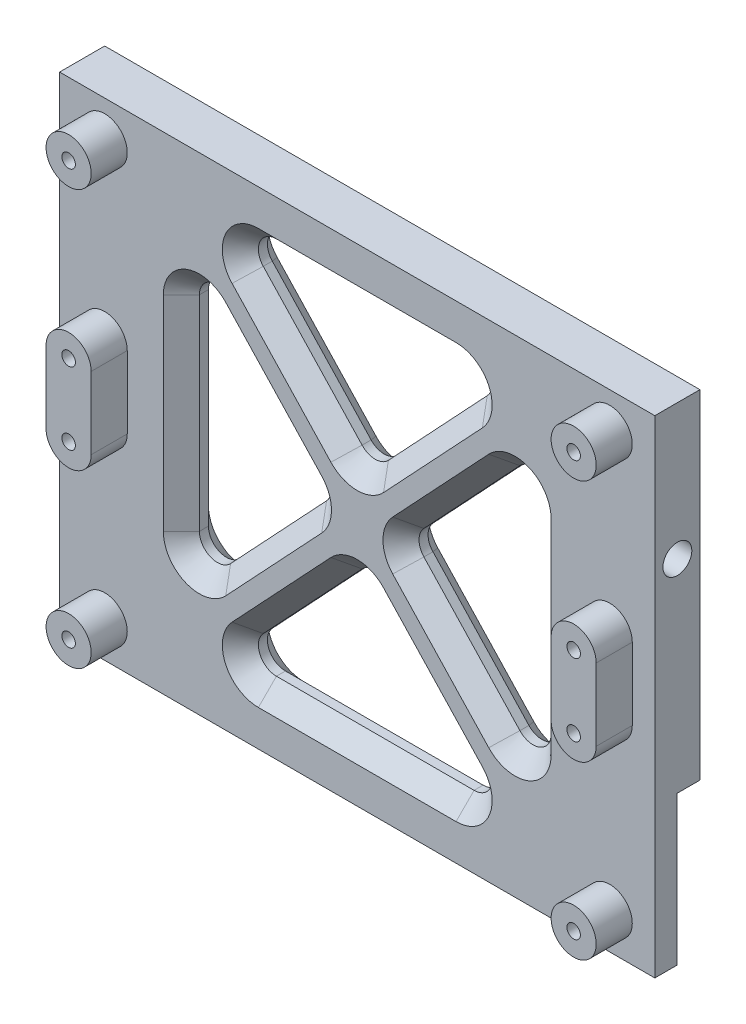
from build123d import *

# Parameters (mm, degrees)
SKETCH1_W           = 66
SKETCH1_H           = 54
BOSS_EXTRUDE1_DEPTH = 5
SKETCH2_R           = 2.5
SKETCH2_R_2         = 0.75
BOSS_EXTRUDE2_DEPTH = 4
SKETCH2_2_R         = 0.75
CUT_EXTRUDE1_DEPTH  = 4
CUT_EXTRUDE2_DEPTH  = 14
SKETCH4_R           = 1.6
SKETCH4_R_2         = 0.75
CUT_EXTRUDE3_DEPTH  = 5
CHAMFER1_SIZE       = 2
CUT_EXTRUDE4_START  = -66
SKETCH5_R           = 1.6
CUT_EXTRUDE4_DEPTH  = 10
SKETCH6_W           = 9.6
SKETCH6_H           = 16.5
CUT_EXTRUDE5_DEPTH  = 2.54


with BuildPart() as part:
    # Sketch1 → Boss-Extrude1 (new body)
    with BuildSketch(Plane.XY):
        Rectangle(SKETCH1_W, SKETCH1_H)
    extrude(amount=BOSS_EXTRUDE1_DEPTH)

    # Sketch2 → Boss-Extrude2 (add)
    with BuildSketch(Plane.XY.offset(5)):
        with Locations((28, -23)):
            Circle(SKETCH2_R)
        with Locations((28, -23)):
            Circle(SKETCH2_R_2, mode=Mode.SUBTRACT)
        with Locations((-28, -23)):
            Circle(SKETCH2_R)
        with Locations((-28, -23)):
            Circle(SKETCH2_R_2, mode=Mode.SUBTRACT)
        with Locations((-28, 23)):
            Circle(SKETCH2_R)
        with Locations((-28, 23)):
            Circle(SKETCH2_R_2, mode=Mode.SUBTRACT)
        with Locations((28, 23)):
            Circle(SKETCH2_R)
        with Locations((28, 23)):
            Circle(SKETCH2_R_2, mode=Mode.SUBTRACT)
        with BuildLine():
            Line((-25.5, 4), (-25.5, -4))
            ThreePointArc((-25.5, -4), (-28, -6.5), (-30.5, -4))
            Line((-30.5, -4), (-30.5, 4))
            ThreePointArc((-30.5, 4), (-28, 6.5), (-25.5, 4))
        make_face()
        with Locations((-28, -4)):
            Circle(SKETCH2_R_2, mode=Mode.SUBTRACT)
        with Locations((-28, 4)):
            Circle(SKETCH2_R_2, mode=Mode.SUBTRACT)
        with BuildLine():
            Line((25.5, 4), (25.5, -4))
            ThreePointArc((25.5, -4), (28, -6.5), (30.5, -4))
            Line((30.5, -4), (30.5, 4))
            ThreePointArc((30.5, 4), (28, 6.5), (25.5, 4))
        make_face()
        with Locations((28, -4)):
            Circle(SKETCH2_R_2, mode=Mode.SUBTRACT)
        with Locations((28, 4)):
            Circle(SKETCH2_R_2, mode=Mode.SUBTRACT)
    extrude(amount=BOSS_EXTRUDE2_DEPTH)

    # Sketch2_2 → Cut-Extrude1 (cut)
    with BuildSketch(Plane.XY.offset(5)):
        with Locations((-28, 23)):
            Circle(SKETCH2_2_R)
        with Locations((28, 23)):
            Circle(SKETCH2_2_R)
        with Locations((28, 4)):
            Circle(SKETCH2_2_R)
        with Locations((28, -4)):
            Circle(SKETCH2_2_R)
        with Locations((28, -23)):
            Circle(SKETCH2_2_R)
        with Locations((-28, -23)):
            Circle(SKETCH2_2_R)
        with Locations((-28, 4)):
            Circle(SKETCH2_2_R)
        with Locations((-28, -4)):
            Circle(SKETCH2_2_R)
    extrude(amount=-CUT_EXTRUDE1_DEPTH, mode=Mode.SUBTRACT)

    # Sketch3 → Cut-Extrude2 (cut)
    with BuildSketch(Plane.XY.offset(5)):
        with BuildLine():
            Line((-16.040925592, 12.723978191), (-5.394585654, 1.367882258))
            ThreePointArc((-5.394585654, 1.367882258), (-4.853660062, 0), (-5.394585654, -1.367882258))
            Line((-5.394585654, -1.367882258), (-16.040925592, -12.723978191))
            ThreePointArc((-16.040925592, -12.723978191), (-18.235476439, -13.21595464), (-19.5, -11.356095934))
            Line((-19.5, -11.356095934), (-19.5, 11.356095934))
            ThreePointArc((-19.5, 11.356095934), (-18.235476439, 13.21595464), (-16.040925592, 12.723978191))
        make_face()
        with BuildLine():
            Line((-10.958839938, 21), (10.958839938, 21))
            ThreePointArc((10.958839938, 21), (12.794019018, 19.795058326), (12.417914346, 17.632117742))
            Line((12.417914346, 17.632117742), (1.459074408, 5.942688475))
            ThreePointArc((1.459074408, 5.942688475), (0, 5.310570733), (-1.459074408, 5.942688475))
            Line((-1.459074408, 5.942688475), (-12.417914346, 17.632117742))
            ThreePointArc((-12.417914346, 17.632117742), (-12.794019018, 19.795058326), (-10.958839938, 21))
        make_face()
        with BuildLine():
            Line((5.394585654, -1.367882258), (16.040925592, -12.723978191))
            ThreePointArc((16.040925592, -12.723978191), (18.235476439, -13.21595464), (19.5, -11.356095934))
            Line((19.5, -11.356095934), (19.5, 11.356095934))
            ThreePointArc((19.5, 11.356095934), (18.235476439, 13.21595464), (16.040925592, 12.723978191))
            Line((16.040925592, 12.723978191), (5.394585654, 1.367882258))
            ThreePointArc((5.394585654, 1.367882258), (4.853660062, 0), (5.394585654, -1.367882258))
        make_face()
        with BuildLine():
            Line((12.417914346, -17.632117742), (1.459074408, -5.942688475))
            ThreePointArc((1.459074408, -5.942688475), (0, -5.310570733), (-1.459074408, -5.942688475))
            Line((-1.459074408, -5.942688475), (-12.417914346, -17.632117742))
            ThreePointArc((-12.417914346, -17.632117742), (-12.794019018, -19.795058326), (-10.958839938, -21))
            Line((-10.958839938, -21), (10.958839938, -21))
            ThreePointArc((10.958839938, -21), (12.794019018, -19.795058326), (12.417914346, -17.632117742))
        make_face()
    extrude(amount=-CUT_EXTRUDE2_DEPTH, mode=Mode.SUBTRACT)

    # Sketch4 → Cut-Extrude3 (cut)
    with BuildSketch(Plane.XZ.offset(27)):
        with Locations((-13, 2.5)):
            Circle(SKETCH4_R)
        with Locations((18, 2.5)):
            Circle(SKETCH4_R_2)
    extrude(amount=-CUT_EXTRUDE3_DEPTH, mode=Mode.SUBTRACT)

    # Chamfer1
    chamfer1_edges = [part.edges().sort_by_distance(p)[0] for p in [
        (6.938494377, -11.787403109, 0),
        (0, -5.310570733, 0),
        (-6.938494377, -11.787403109, 0),
        (-12.794019018, -19.795058326, 0),
        (0, -21, 0),
        (12.794019018, -19.795058326, 0),
        (-10.717755623, -7.045930225, 0),
        (-4.853660062, 0, 0),
        (-10.717755623, 7.045930225, 0),
        (-18.235476439, 13.21595464, 0),
        (-19.5, 0, 0),
        (-18.235476439, -13.21595464, 0),
        (10.717755623, -7.045930225, 0),
        (18.235476439, -13.21595464, 0),
        (19.5, 0, 0),
        (18.235476439, 13.21595464, 0),
        (10.717755623, 7.045930225, 0),
        (4.853660062, 0, 0),
        (6.938494377, 11.787403109, 0),
        (12.794019018, 19.795058326, 0),
        (0, 21, 0),
        (-12.794019018, 19.795058326, 0),
        (-6.938494377, 11.787403109, 0),
        (0, 5.310570733, 0),
        (0, 5.310570733, 5),
        (6.938494377, 11.787403109, 5),
        (12.794019018, 19.795058326, 5),
        (0, 21, 5),
        (-12.794019018, 19.795058326, 5),
        (-6.938494377, 11.787403109, 5),
        (4.853660062, 0, 5),
        (10.717755623, -7.045930225, 5),
        (18.235476439, -13.21595464, 5),
        (19.5, 0, 5),
        (18.235476439, 13.21595464, 5),
        (10.717755623, 7.045930225, 5),
        (-18.235476439, -13.21595464, 5),
        (-10.717755623, -7.045930225, 5),
        (-4.853660062, 0, 5),
        (-10.717755623, 7.045930225, 5),
        (-18.235476439, 13.21595464, 5),
        (-19.5, 0, 5),
        (12.794019018, -19.795058326, 5),
        (6.938494377, -11.787403109, 5),
        (0, -5.310570733, 5),
        (-6.938494377, -11.787403109, 5),
        (-12.794019018, -19.795058326, 5),
        (0, -21, 5),
    ]]
    chamfer(chamfer1_edges, length=CHAMFER1_SIZE)

    # Sketch5 → Cut-Extrude4 (cut)
    with BuildSketch(Plane.ZY.offset(33).offset(CUT_EXTRUDE4_START)):
        with Locations((2.5, 12)):
            Circle(SKETCH5_R)
    extrude(amount=CUT_EXTRUDE4_DEPTH, mode=Mode.SUBTRACT)

    # Sketch6 → Cut-Extrude5 (cut)
    with BuildSketch(Plane(origin=(0, 0, 0), x_dir=(-1, 0, 0), z_dir=(0, 0, -1))):
        with Locations((-28.2, -18.75)):
            Rectangle(SKETCH6_W, SKETCH6_H)
    extrude(amount=-CUT_EXTRUDE5_DEPTH, mode=Mode.SUBTRACT)


solid = part.part
